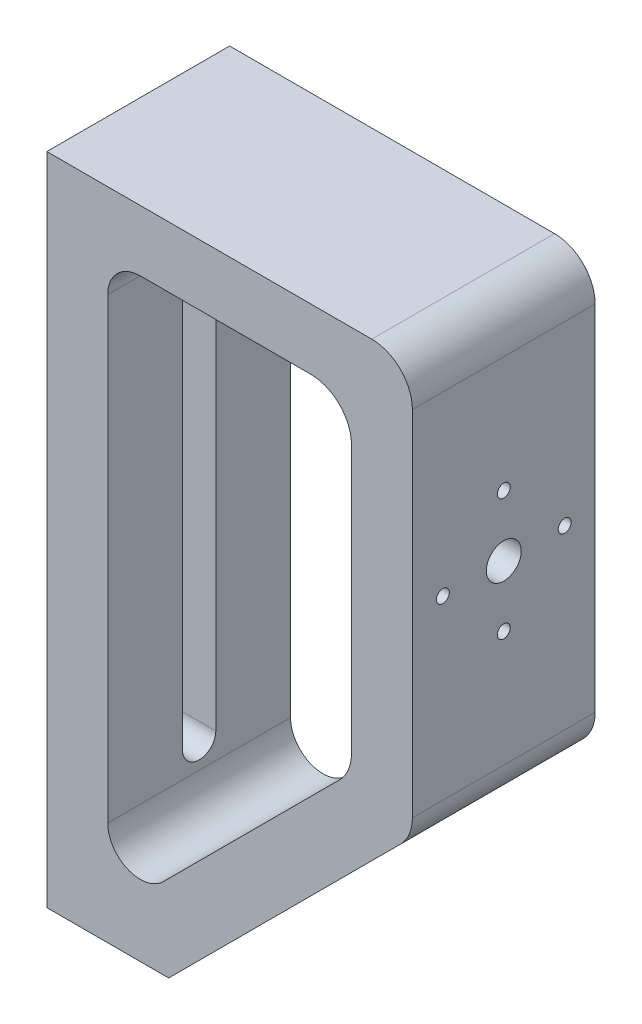
from build123d import *

# Parameters (mm, degrees)
BODY_DEPTH                             = 45
BOTTOM_TRIM_SIZE                       = 30
BOTTOM_TRIM_SIZE2                      = 42.426406871
FRONT_MOUNTING_HOLES_REACH             = 92
SKETCH2_R                              = 4.3
SKETCH2_R_2                            = 1.6
FRONT_MOUNTING_HOLES_COUNTERBORE_DEPTH = 3.5
BACK_MOUNTING_SLOT_REACH               = 92


with BuildPart() as part:
    # Sketch1 → Body (new body)
    with BuildSketch(Plane.XY):
        with BuildLine():
            Line((0, 0), (0, 191.213203436))
            Line((0, 191.213203436), (80, 191.213203436))
            ThreePointArc((80, 191.213203436), (87.071067812, 188.284271247), (90, 181.213203436))
            Line((90, 181.213203436), (90, 94.142135624))
            ThreePointArc((90, 94.142135624), (89.238795325, 90.3153013), (87.071067812, 87.071067812))
            Line((87.071067812, 87.071067812), (0, 0))
        make_face()
        with BuildLine():
            Line((72.071067812, 93.284271247), (28.656854249, 49.870057685))
            ThreePointArc((28.656854249, 49.870057685), (19.938532541, 48.135875674), (15, 55.526911935))
            Line((15, 55.526911935), (15, 168.213203436))
            ThreePointArc((15, 168.213203436), (17.343145751, 173.870057685), (23, 176.213203436))
            Line((23, 176.213203436), (65, 176.213203436))
            ThreePointArc((65, 176.213203436), (72.071067812, 173.284271247), (75, 166.213203436))
            Line((75, 166.213203436), (75, 100.355339059))
            ThreePointArc((75, 100.355339059), (74.238795325, 96.528504736), (72.071067812, 93.284271247))
        make_face(mode=Mode.SUBTRACT)
    extrude(amount=BODY_DEPTH)

    # Bottom Trim
    bottom_trim_edges = [part.edges().sort_by_distance(p)[0] for p in [
        (0, 0, 22.5),
    ]]
    bottom_trim_side = [part.faces().sort_by_distance(p)[0] for p in [
        (0, 95.606601718, 22.5),
    ]]
    chamfer(bottom_trim_edges, length=BOTTOM_TRIM_SIZE, length2=BOTTOM_TRIM_SIZE2, reference=bottom_trim_side[0])

    # Sketch2 → Front Mounting Holes (cut, up to next)
    with BuildSketch(Plane(origin=(90, 0, 0), x_dir=(0, 0, -1), z_dir=(1, 0, 0)), mode=Mode.PRIVATE) as front_mounting_holes_sk1:
        with Locations((-22.5, 137.67766953)):
            Circle(SKETCH2_R)
    front_mounting_holes_tool1 = extrude(front_mounting_holes_sk1.sketch, amount=-FRONT_MOUNTING_HOLES_REACH, mode=Mode.PRIVATE) & part.part
    add(front_mounting_holes_tool1.solids().sort_by_distance((90, 137.67767, 22.5))[0], mode=Mode.SUBTRACT)
    # Sketch2 → Front Mounting Holes (cut, up to next)
    with BuildSketch(Plane(origin=(90, 0, 0), x_dir=(0, 0, -1), z_dir=(1, 0, 0)), mode=Mode.PRIVATE) as front_mounting_holes_sk2:
        with Locations((-22.5, 152.67766953)):
            Circle(SKETCH2_R_2)
    front_mounting_holes_tool2 = extrude(front_mounting_holes_sk2.sketch, amount=-FRONT_MOUNTING_HOLES_REACH, mode=Mode.PRIVATE) & part.part
    add(front_mounting_holes_tool2.solids().sort_by_distance((90, 152.67767, 22.5))[0], mode=Mode.SUBTRACT)
    # Sketch2 → Front Mounting Holes (cut, up to next)
    with BuildSketch(Plane(origin=(90, 0, 0), x_dir=(0, 0, -1), z_dir=(1, 0, 0)), mode=Mode.PRIVATE) as front_mounting_holes_sk3:
        with Locations((-7.5, 137.67766953)):
            Circle(SKETCH2_R_2)
    front_mounting_holes_tool3 = extrude(front_mounting_holes_sk3.sketch, amount=-FRONT_MOUNTING_HOLES_REACH, mode=Mode.PRIVATE) & part.part
    add(front_mounting_holes_tool3.solids().sort_by_distance((90, 137.67767, 7.5))[0], mode=Mode.SUBTRACT)
    # Sketch2 → Front Mounting Holes (cut, up to next)
    with BuildSketch(Plane(origin=(90, 0, 0), x_dir=(0, 0, -1), z_dir=(1, 0, 0)), mode=Mode.PRIVATE) as front_mounting_holes_sk4:
        with Locations((-22.5, 122.67766953)):
            Circle(SKETCH2_R_2)
    front_mounting_holes_tool4 = extrude(front_mounting_holes_sk4.sketch, amount=-FRONT_MOUNTING_HOLES_REACH, mode=Mode.PRIVATE) & part.part
    add(front_mounting_holes_tool4.solids().sort_by_distance((90, 122.67767, 22.5))[0], mode=Mode.SUBTRACT)
    # Sketch2 → Front Mounting Holes (cut, up to next)
    with BuildSketch(Plane(origin=(90, 0, 0), x_dir=(0, 0, -1), z_dir=(1, 0, 0)), mode=Mode.PRIVATE) as front_mounting_holes_sk5:
        with Locations((-37.5, 137.67766953)):
            Circle(SKETCH2_R_2)
    front_mounting_holes_tool5 = extrude(front_mounting_holes_sk5.sketch, amount=-FRONT_MOUNTING_HOLES_REACH, mode=Mode.PRIVATE) & part.part
    add(front_mounting_holes_tool5.solids().sort_by_distance((90, 137.67767, 37.5))[0], mode=Mode.SUBTRACT)

    # Sketch3 → Front Mounting Holes Counterbore (cut)
    with BuildSketch(Plane.ZY.offset(-75)):
        Polygon((40.35, 136.032221262), (40.35, 139.323117797), (37.5, 140.968566064), (34.65, 139.323117797), (34.65, 136.032221262), (37.5, 134.386772995), align=None)
        Polygon((24.145448267, 155.52766953), (20.854551733, 155.52766953), (19.209103466, 152.67766953), (20.854551733, 149.82766953), (24.145448267, 149.82766953), (25.790896534, 152.67766953), align=None)
        Polygon((20.854551733, 119.82766953), (24.145448267, 119.82766953), (25.790896534, 122.67766953), (24.145448267, 125.52766953), (20.854551733, 125.52766953), (19.209103466, 122.67766953), align=None)
        Polygon((4.65, 139.323117797), (4.65, 136.032221262), (7.5, 134.386772995), (10.35, 136.032221262), (10.35, 139.323117797), (7.5, 140.968566064), align=None)
    extrude(amount=-FRONT_MOUNTING_HOLES_COUNTERBORE_DEPTH, mode=Mode.SUBTRACT)

    # Sketch4 → Back Mounting Slot (cut, up to next)
    with BuildSketch(Plane.ZY, mode=Mode.PRIVATE) as back_mounting_slot_sk1:
        with BuildLine():
            Line((26.6, 161.870057685), (26.6, 61.870057685))
            ThreePointArc((26.6, 61.870057685), (22.5, 57.770057685), (18.4, 61.870057685))
            Line((18.4, 61.870057685), (18.4, 161.870057685))
            ThreePointArc((18.4, 161.870057685), (22.5, 165.970057685), (26.6, 161.870057685))
        make_face()
    back_mounting_slot_tool1 = extrude(back_mounting_slot_sk1.sketch, amount=-BACK_MOUNTING_SLOT_REACH, mode=Mode.PRIVATE) & part.part
    add(back_mounting_slot_tool1.solids().sort_by_distance((0, 111.870058, 22.5))[0], mode=Mode.SUBTRACT)


solid = part.part
